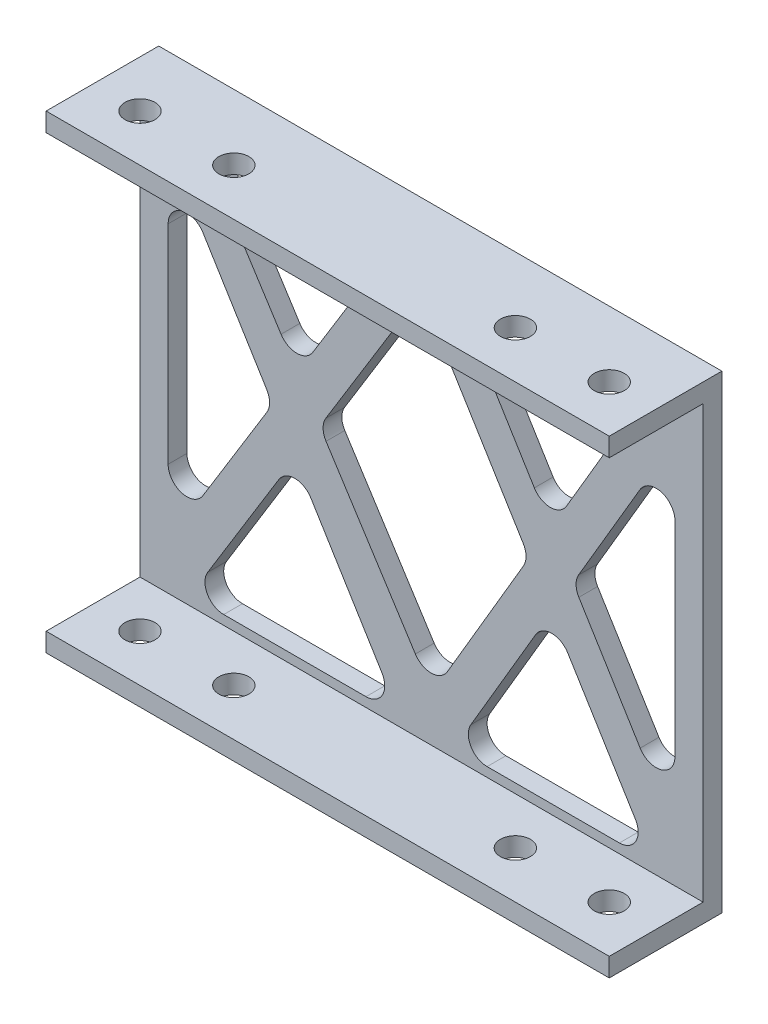
from build123d import *

# Parameters (mm, degrees)
SKETCH_1_W          = 60
SKETCH_1_H          = 50
EXTRUDE_1_DEPTH     = 2
SKETCH_2_W          = 10
SKETCH_2_H          = 2
EXTRUDE_2_DEPTH     = 60
SKETCH_3_R          = 1.6
CUT_EXTRUDE_1_DEPTH = 51
FILLET_1_R          = 2


with BuildPart() as part:
    # 草图1 → 凸台-拉伸1 (new body)
    with BuildSketch(Plane.XY):
        with Locations((-50.970873786, -63.980582524)):
            Rectangle(SKETCH_1_W, SKETCH_1_H)
        Polygon((-77.970873786, -45.804555709), (-77.970873786, -82.156609339), (-66.817402786, -63.980582524), align=None, mode=Mode.SUBTRACT)
        Polygon((-75.624344787, -85.980582524), (-53.317402786, -85.980582524), (-64.470873786, -67.804555709), align=None, mode=Mode.SUBTRACT)
        Polygon((-23.970873786, -45.9315118), (-23.970873786, -82.156609339), (-34.838542531, -64.446334348), align=None, mode=Mode.SUBTRACT)
        Polygon((-75.596017187, -41.980582524), (-53.317402786, -41.980582524), (-64.219831603, -59.747503559), align=None, mode=Mode.SUBTRACT)
        Polygon((-50.970873786, -45.804555709), (-39.503543881, -64.492056295), (-49.871707725, -82.155891862), (-61.82340345, -63.490159606), align=None, mode=Mode.SUBTRACT)
        Polygon((-26.289955727, -41.980582524), (-37.209130522, -60.583153918), (-48.624344787, -41.980582524), align=None, mode=Mode.SUBTRACT)
        Polygon((-37.13295589, -68.355236725), (-26.317402786, -85.980582524), (-47.478527346, -85.980582524), align=None, mode=Mode.SUBTRACT)
    extrude(amount=EXTRUDE_1_DEPTH)

    # 草图2 → 凸台-拉伸2 (add)
    with BuildSketch(Plane(origin=(-20.970873786, 0, 0), x_dir=(0, 0, -1), z_dir=(1, 0, 0))):
        with Locations((-7, -87.980582524)):
            Rectangle(SKETCH_2_W, SKETCH_2_H)
        with Locations((-7, -39.980582524)):
            Rectangle(SKETCH_2_W, SKETCH_2_H)
    extrude(amount=-EXTRUDE_2_DEPTH)

    # 草图3 → 切除-拉伸1 (cut, through all)
    with BuildSketch(Plane(origin=(0, -38.980582524, 0), x_dir=(1, 0, 0), z_dir=(0, 1, 0))):
        with Locations((-75.970873786, -7)):
            Circle(SKETCH_3_R)
        with Locations((-65.970873786, -7)):
            Circle(SKETCH_3_R)
        with Locations((-35.970873786, -7)):
            Circle(SKETCH_3_R)
        with Locations((-25.970873786, -7)):
            Circle(SKETCH_3_R)
    extrude(amount=-CUT_EXTRUDE_1_DEPTH, mode=Mode.SUBTRACT)

    # 圆角1
    fillet_1_edges = [part.edges().sort_by_distance(p)[0] for p in [
        (-50.970873786, -45.804555709, 1),
        (-61.82340345, -63.490159606, 1),
        (-49.871707725, -82.155891862, 1),
        (-39.503543881, -64.492056295, 1),
        (-66.817402786, -63.980582524, 1),
        (-77.970873786, -45.804555709, 1),
        (-77.970873786, -82.156609339, 1),
        (-75.596017187, -41.980582524, 1),
        (-64.219831603, -59.747503559, 1),
        (-53.317402786, -41.980582524, 1),
        (-26.289955727, -41.980582524, 1),
        (-48.624344787, -41.980582524, 1),
        (-37.209130522, -60.583153918, 1),
        (-23.970873786, -45.9315118, 1),
        (-34.838542531, -64.446334348, 1),
        (-23.970873786, -82.156609339, 1),
        (-64.470873786, -67.804555709, 1),
        (-75.624344787, -85.980582524, 1),
        (-53.317402786, -85.980582524, 1),
        (-47.478527346, -85.980582524, 1),
        (-26.317402786, -85.980582524, 1),
        (-37.13295589, -68.355236725, 1),
    ]]
    fillet(fillet_1_edges, radius=FILLET_1_R)


solid = part.part
